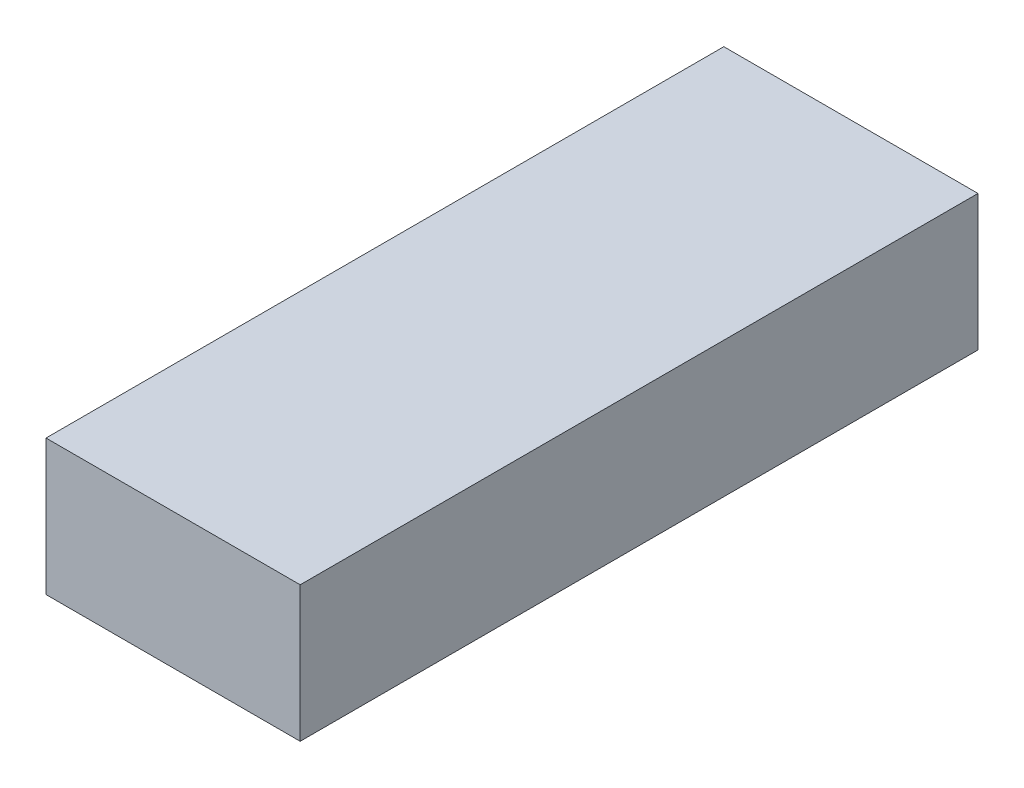
from build123d import *

# Parameters (mm, degrees)
CROQUIS1_W              = 150
CROQUIS1_H              = 80
CROQUIS1_W_2            = 140
CROQUIS1_H_2            = 70
SALIENTE_EXTRUIR1_DEPTH = 400
CROQUIS2_W              = 150
CROQUIS2_H              = 80
SALIENTE_EXTRUIR2_DEPTH = 5


with BuildPart() as part:
    # Croquis1 → Saliente-Extruir1 (new body)
    with BuildSketch(Plane.XY):
        Rectangle(CROQUIS1_W, CROQUIS1_H)
        Rectangle(CROQUIS1_W_2, CROQUIS1_H_2, mode=Mode.SUBTRACT)
    extrude(amount=SALIENTE_EXTRUIR1_DEPTH)

    # Croquis2 → Saliente-Extruir2 (add)
    with BuildSketch(Plane.XY.offset(400)):
        Rectangle(CROQUIS2_W, CROQUIS2_H)
    extrude(amount=-SALIENTE_EXTRUIR2_DEPTH)


solid = part.part
